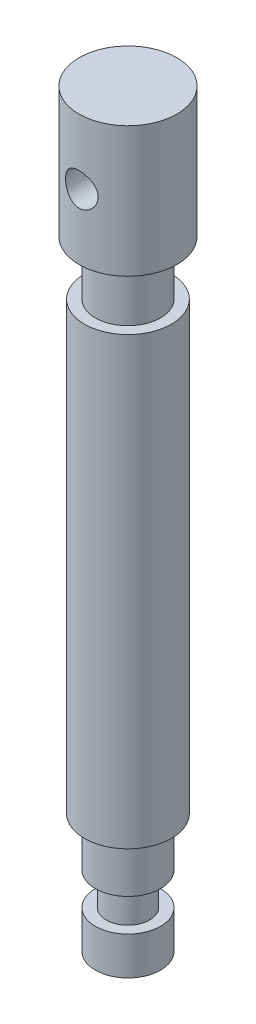
from build123d import *

# Parameters (mm, degrees)
SKETCH3_R               = 3
CUT_EXTRUDE1_DEPTH      = 10
CUT_EXTRUDE1_DEPTH_BACK = 10


with BuildPart() as part:
    # Sketch2 → Revolve1 (revolve)
    with BuildSketch(Plane.XY):
        Polygon((0, 0), (6, 0), (6, 7), (4, 7), (4, 13), (6, 13), (6, 22), (8, 22), (8, 104), (6, 104), (6, 114), (9, 114), (9, 138), (0, 138), align=None)
    revolve(axis=Axis((0, 138, 0), (0, -1, 0)))

    # Sketch3 → Cut-Extrude1 (cut, two sides)
    with BuildSketch(Plane.XY) as cut_extrude1_sk:
        with Locations((0, 126)):
            Circle(SKETCH3_R)
    extrude(amount=CUT_EXTRUDE1_DEPTH, mode=Mode.SUBTRACT)
    extrude(cut_extrude1_sk.sketch, amount=-CUT_EXTRUDE1_DEPTH_BACK, mode=Mode.SUBTRACT)


solid = part.part
